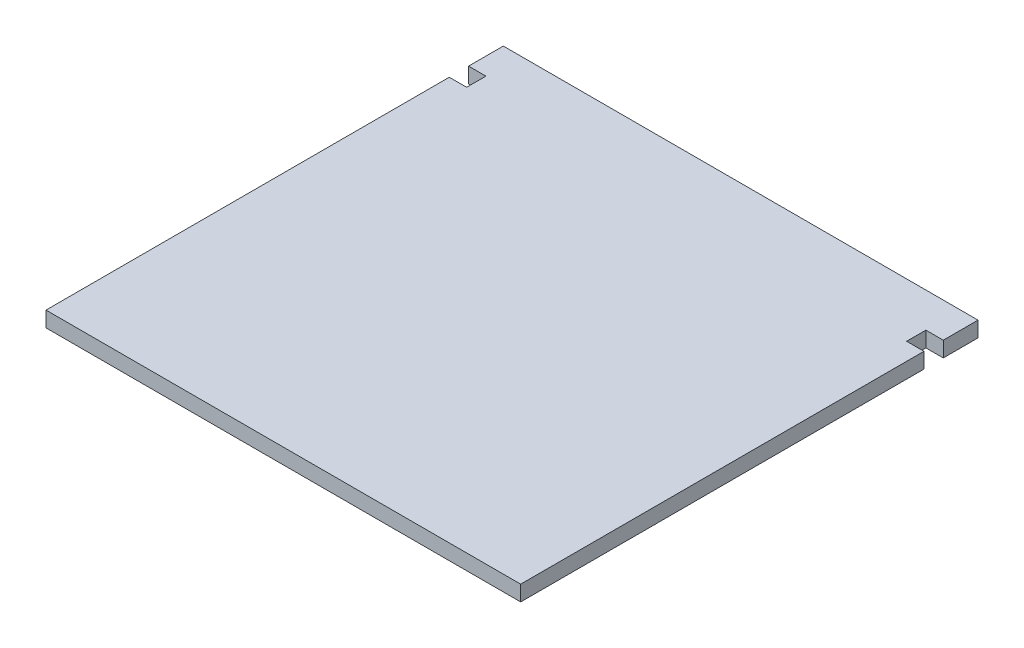
from build123d import *

# Parameters (mm, degrees)
EXTRUDE_1_DEPTH = 4


with BuildPart() as part:
    # Эскиз1 → Бобышка-Вытянуть1 (new body)
    with BuildSketch(Plane(origin=(0, 0, 0), x_dir=(1, 0, 0), z_dir=(0, 1, 0))):
        Polygon((61.5, 0), (-61.5, 0), (-61.5, 104.5), (-57, 104.5), (-57, 109.5), (-61.5, 109.5), (-61.5, 118.5), (61.5, 118.5), (61.5, 109.5), (57, 109.5), (57, 104.5), (61.5, 104.5), align=None)
    extrude(amount=EXTRUDE_1_DEPTH)


solid = part.part
